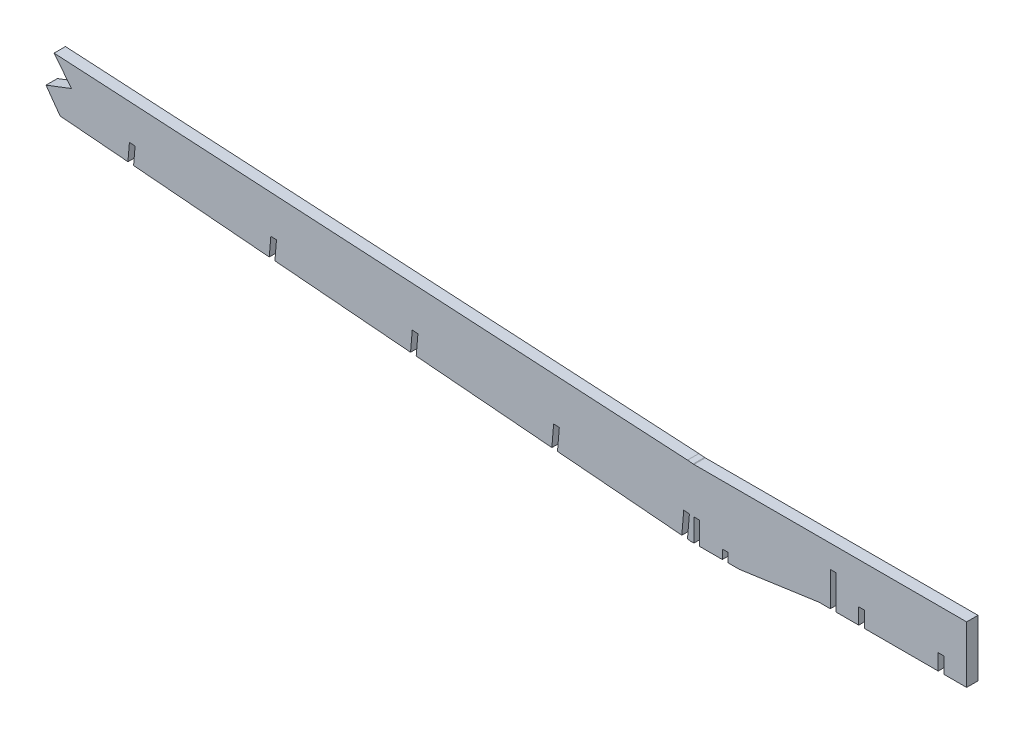
from build123d import *

# Parameters (mm, degrees)
BOSS_EXTRUDE1_DEPTH = 3.175
CUT_EXTRUDE1_DEPTH  = 7.35
CUT_EXTRUDE2_DEPTH  = 7.62


with BuildPart() as part:
    # Sketch1 → Boss-Extrude1 (new body, symmetric)
    with BuildSketch(Plane.XY):
        Polygon((76.2, 37.697541537), (76.2, 56.747541537), (79.375, 56.747541537), (79.375, 37.697541537), (92.075, 37.697541537), (92.075, 46.587541537), (95.25, 46.587541537), (95.25, 37.697541537), (136.525, 37.697541537), (136.525, 46.587541537), (139.7, 46.587541537), (139.7, 37.697541537), (152.4, 37.697541537), (152.4, 69.447541537), (0, 69.447541537), (-0.423998633, 69.491926731), (-3.587863461, 69.757603883), (-946.051908629, 122.953392794), (-946.583462345, 116.623288424), (-943.412318182, 116.444298555), (-943.91275138, 110.48479854), (-6.775989292, 31.791225946), (-5.713280681, 44.446685258), (-2.549415853, 44.181008106), (-3.612124464, 31.525548794), (-1.492292584, 31.347541537), (0, 31.347541537), (0, 44.047541537), (3.175, 44.047541537), (3.175, 31.347541537), (15.875, 31.347541537), (15.875, 36.427541537), (19.05, 36.427541537), (19.05, 31.347541537), (25.4, 31.347541537), (69.85, 37.697541537), align=None)
    extrude(amount=BOSS_EXTRUDE1_DEPTH, both=True)

    # Sketch2 → Cut-Extrude1 (cut, through all)
    with BuildSketch(Plane.XY.offset(3.175)):
        Polygon((-76.254460917, 37.625496217), (-75.245037036, 49.646404609), (-78.411328309, 49.883186), (-79.418325745, 37.891173369), align=None)
        Polygon((-155.224527027, 44.256797945), (-154.27566721, 55.556468134), (-157.441958483, 55.793249525), (-158.388391855, 44.522475098), align=None)
        Polygon((-234.194593137, 50.888099674), (-233.306297384, 61.466531659), (-236.472588657, 61.70331305), (-237.358457965, 51.153776826), align=None)
        Polygon((-313.164659247, 57.519401402), (-312.336927558, 67.376595183), (-315.503218831, 67.613376574), (-316.328524075, 57.785078555), align=None)
        Polygon((-392.134725356, 64.15070313), (-391.367557732, 73.286658708), (-394.533849005, 73.523440099), (-395.298590185, 64.416380283), align=None)
        Polygon((-471.104791466, 70.782004859), (-470.398187906, 79.196722233), (-473.564479179, 79.433503624), (-474.268656294, 71.047682011), align=None)
        Polygon((-550.074857576, 77.413306587), (-549.42881808, 85.106785757), (-552.595109353, 85.343567149), (-553.238722404, 77.67898374), align=None)
        Polygon((-629.044923686, 84.044608316), (-628.459448254, 91.016849282), (-631.625739527, 91.253630673), (-632.208788514, 84.310285468), align=None)
        Polygon((-708.014989796, 90.675910044), (-707.490078428, 96.926912807), (-710.656369701, 97.163694198), (-711.178854624, 90.941587197), align=None)
        Polygon((-786.985055905, 97.307211772), (-786.520708602, 102.836976331), (-789.686999875, 103.073757723), (-790.148920734, 97.572888925), align=None)
        Polygon((-865.955122015, 103.938513501), (-865.551338776, 108.747039856), (-868.717630049, 108.983821247), (-869.118986843, 104.204190653), align=None)
    extrude(amount=-CUT_EXTRUDE1_DEPTH, mode=Mode.SUBTRACT)

    # Sketch3 → Cut-Extrude2 (cut)
    with BuildSketch(Plane.XY.offset(3.175)):
        Polygon((-354.231624716, 60.967890842), (-362.126685184, 71.979397876), (-347.872352174, 77.449083798), (-357.599036746, 89.739165772), (-993.791218606, 254.183288708), (-993.791218606, 28.735079887), align=None)
    extrude(amount=-CUT_EXTRUDE2_DEPTH, mode=Mode.SUBTRACT)


solid = part.part
